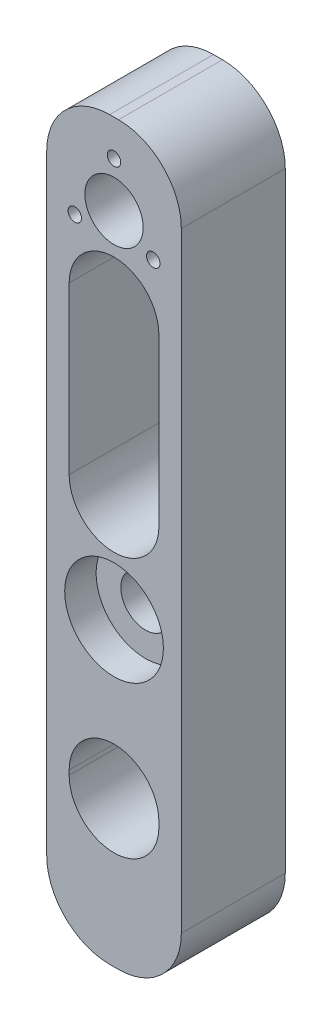
from build123d import *

# Parameters (mm, degrees)
SKETCH1_W           = 30
SKETCH1_H           = 84
SKETCH1_R           = 7.982312081
SKETCH1_R_2         = 11
BOSS_EXTRUDE1_DEPTH = 23.1638
SKETCH2_R           = 7.982312081
SKETCH2_R_2         = 4
BOSS_EXTRUDE2_DEPTH = 23.1638
SKETCH3_R           = 4
BOSS_EXTRUDE3_DEPTH = 32.1638
SKETCH4_R           = 11
SKETCH4_R_2         = 5.5
BOSS_EXTRUDE4_DEPTH = 16.1638
FILLET1_R           = 14
SKETCH5_W           = 30
SKETCH5_H           = 80
BOSS_EXTRUDE5_DEPTH = 23.1638
SKETCH6_R           = 1.5
SKETCH6_R_2         = 6.5
CUT_EXTRUDE1_DEPTH  = 33.1638
CUT_EXTRUDE2_DEPTH  = 23.1638
FILLET2_R           = 14


with BuildPart() as part:
    # Sketch1 → Boss-Extrude1 (new body)
    with BuildSketch(Plane.XY):
        with Locations((0, 25)):
            Rectangle(SKETCH1_W, SKETCH1_H)
        Circle(SKETCH1_R, mode=Mode.SUBTRACT)
        with Locations((0, 50)):
            Circle(SKETCH1_R_2, mode=Mode.SUBTRACT)
    extrude(amount=BOSS_EXTRUDE1_DEPTH)

    # Sketch2 → Boss-Extrude2 (add)
    with BuildSketch(Plane.XY.offset(23.1638)):
        Circle(SKETCH2_R)
        Circle(SKETCH2_R_2, mode=Mode.SUBTRACT)
    extrude(amount=-BOSS_EXTRUDE2_DEPTH)

    # Sketch3 → Boss-Extrude3 (add)
    with BuildSketch(Plane.XY.offset(23.1638)):
        Circle(SKETCH3_R)
    extrude(amount=-BOSS_EXTRUDE3_DEPTH)

    # Sketch4 → Boss-Extrude4 (add)
    with BuildSketch(Plane(origin=(0, 0, 0), x_dir=(-1, 0, 0), z_dir=(0, 0, -1))):
        with Locations((0, 50)):
            Circle(SKETCH4_R)
        with Locations((0, 50)):
            Circle(SKETCH4_R_2, mode=Mode.SUBTRACT)
    extrude(amount=-BOSS_EXTRUDE4_DEPTH)

    # Fillet1
    fillet1_edges = [part.edges().sort_by_distance(p)[0] for p in [
        (15, -17, 11.5819),
        (-15, -17, 11.5819),
    ]]
    fillet(fillet1_edges, radius=FILLET1_R)

    # Sketch5 → Boss-Extrude5 (add)
    with BuildSketch(Plane.XY.offset(23.1638)):
        with Locations((0, 107)):
            Rectangle(SKETCH5_W, SKETCH5_H)
    extrude(amount=-BOSS_EXTRUDE5_DEPTH)

    # Sketch6 → Cut-Extrude1 (cut, through all)
    with BuildSketch(Plane.XY.offset(23.1638)):
        with Locations((-8.75, 123.844555434)):
            Circle(SKETCH6_R)
        with Locations((8.75, 123.844555434)):
            Circle(SKETCH6_R)
        with Locations((0, 139)):
            Circle(SKETCH6_R)
        with Locations((0, 128.896370289)):
            Circle(SKETCH6_R_2)
    extrude(amount=-CUT_EXTRUDE1_DEPTH, mode=Mode.SUBTRACT)

    # Sketch7 → Cut-Extrude2 (cut)
    with BuildSketch(Plane.XY.offset(23.1638)):
        with BuildLine():
            Line((-10, 110), (-10, 73))
            ThreePointArc((-10, 73), (0, 63), (10, 73))
            Line((10, 73), (10, 110))
            ThreePointArc((10, 110), (0, 120), (-10, 110))
        make_face()
        with BuildLine():
            Line((-10, 16), (-10, 15))
            ThreePointArc((-10, 15), (0, 5), (10, 15))
            Line((10, 15), (10, 16))
            ThreePointArc((10, 16), (0, 26), (-10, 16))
        make_face()
    extrude(amount=-CUT_EXTRUDE2_DEPTH, mode=Mode.SUBTRACT)

    # Fillet2
    fillet2_edges = [part.edges().sort_by_distance(p)[0] for p in [
        (-15, 147, 11.5819),
        (15, 147, 11.5819),
    ]]
    fillet(fillet2_edges, radius=FILLET2_R)


solid = part.part
